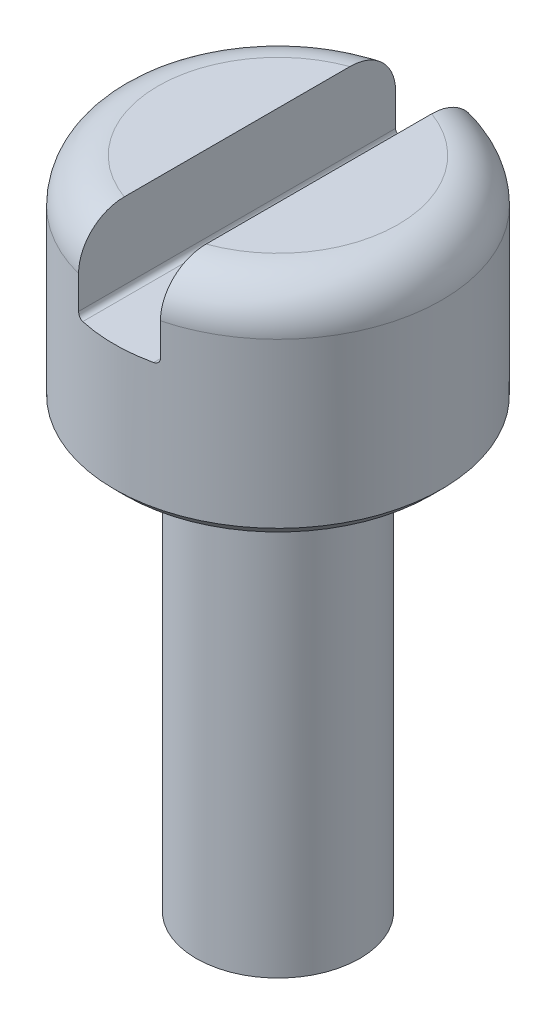
from build123d import *

# Parameters (mm, degrees)
SKETCH1_R           = 1.5
BOSS_EXTRUDE1_DEPTH = 2
SKETCH2_W           = 0.75
SKETCH2_H           = 1.5
CUT_EXTRUDE1_DEPTH  = 6
SKETCH3_R           = 0.75
BOSS_EXTRUDE2_DEPTH = 4
FILLET1_R           = 0.05
CHAMFER2_SIZE       = 0.1
FILLET2_R           = 0.4


with BuildPart() as part:
    # Sketch1 → Boss-Extrude1 (new body)
    with BuildSketch(Plane(origin=(0, 0, 0), x_dir=(1, 0, 0), z_dir=(0, 1, 0))):
        Circle(SKETCH1_R)
    extrude(amount=BOSS_EXTRUDE1_DEPTH)

    # Sketch2 → Cut-Extrude1 (cut, symmetric)
    with BuildSketch(Plane.XY):
        with Locations((0, 2)):
            Rectangle(SKETCH2_W, SKETCH2_H)
    extrude(amount=CUT_EXTRUDE1_DEPTH, both=True, mode=Mode.SUBTRACT)

    # Sketch3 → Boss-Extrude2 (add)
    with BuildSketch(Plane.XZ):
        Circle(SKETCH3_R)
    extrude(amount=BOSS_EXTRUDE2_DEPTH)

    # Fillet1
    fillet1_edges = [part.edges().sort_by_distance(p)[0] for p in [
        (-0.375, 1.25, 0),
        (0.375, 1.25, 0),
    ]]
    fillet(fillet1_edges, radius=FILLET1_R)

    # Chamfer2
    chamfer2_edges = [part.edges().sort_by_distance(p)[0] for p in [
        (-1.5, 0, 0),
    ]]
    chamfer(chamfer2_edges, length=CHAMFER2_SIZE)

    # Fillet2
    fillet2_edges = [part.edges().sort_by_distance(p)[0] for p in [
        (1.185854123, 2, 0.918558654),
        (-1.5, 2, 0),
    ]]
    fillet(fillet2_edges, radius=FILLET2_R)


solid = part.part
